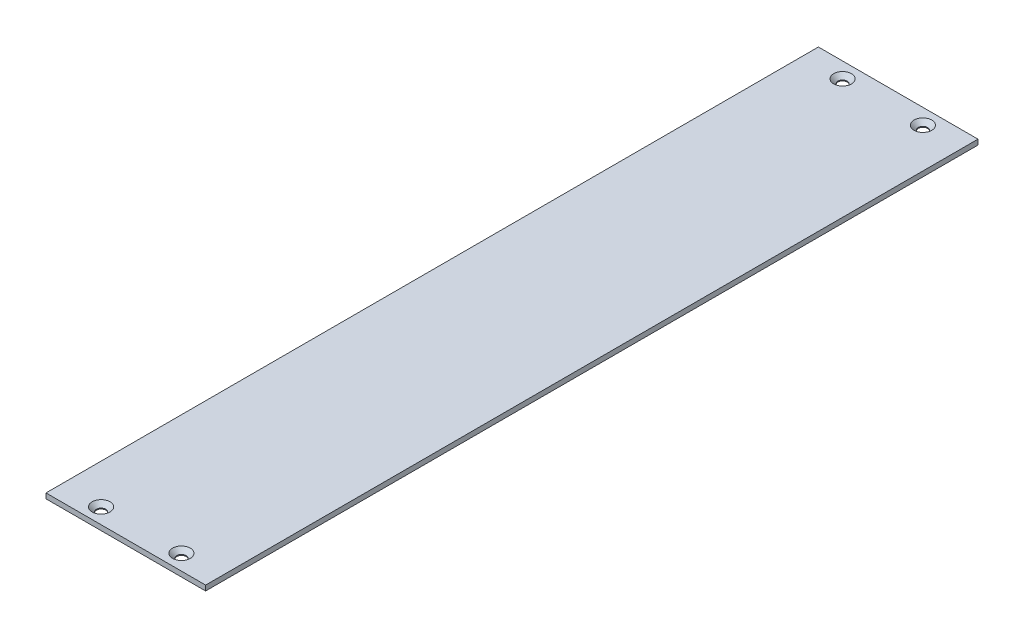
from build123d import *

# Parameters (mm, degrees)
SKETCH1_W           = 155
SKETCH1_H           = 750
BOSS_EXTRUDE1_DEPTH = 5


with BuildPart() as part:
    # Sketch1 → Boss-Extrude1 (new body)
    with BuildSketch(Plane(origin=(0, 0, 0), x_dir=(1, 0, 0), z_dir=(0, 1, 0))):
        with Locations((77.5, -375)):
            Rectangle(SKETCH1_W, SKETCH1_H)
    extrude(amount=BOSS_EXTRUDE1_DEPTH)

    # Sketch24 → CSK for M8 Flat Head Machine Screw1 (revolve, cut)
    with BuildSketch(Plane(origin=(116.5, 5, 15), x_dir=(0, 0, 1), z_dir=(1, 0, 0))):
        Polygon((0, 0), (0, 5), (4.5, 5), (4.5, 4.15), (8.65, 0), align=None)
    csk_for_m8_flat_head_machine_screw1 = revolve(axis=Axis((116.5, 11.35, 15), (0, -1, 0)), mode=Mode.SUBTRACT)

    # Mirror1: CSK for M8 Flat Head Machine Screw1 across plane
    add(csk_for_m8_flat_head_machine_screw1.mirror(Plane(origin=(0, 0, 375), x_dir=(1, 0, 0), z_dir=(0, 0, -1))), mode=Mode.SUBTRACT)

    # Mirror2: CSK for M8 Flat Head Machine Screw1 across plane
    add(csk_for_m8_flat_head_machine_screw1.mirror(Plane(origin=(77.5, 0, 0), x_dir=(0, 0, 1), z_dir=(1, 0, 0))), mode=Mode.SUBTRACT)

    # Mirror2 copy 1 sketch → Mirror2 copy 1 (revolve, cut)
    with BuildSketch(Plane(origin=(38.5, 5, 735), x_dir=(0, 0, -1), z_dir=(-1, 0, 0))):
        Polygon((0, 0), (0, 5), (4.5, 5), (4.5, 4.15), (8.65, 0), align=None)
    revolve(axis=Axis((38.5, 11.35, 735), (0, -1, 0)), mode=Mode.SUBTRACT)


solid = part.part
